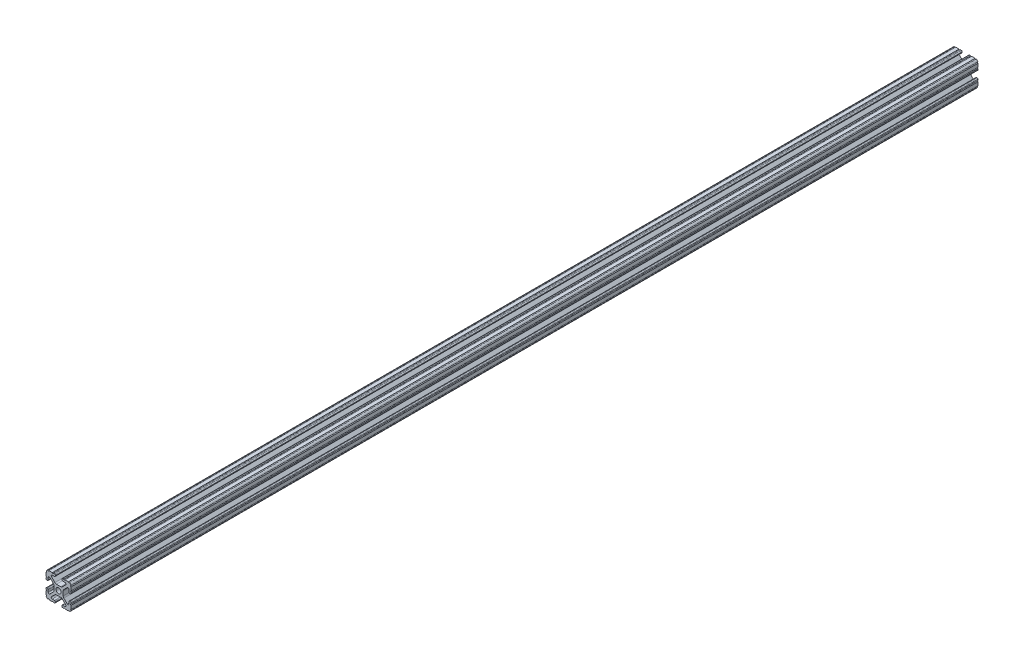
from build123d import *

# Parameters (mm, degrees)
BOSS_EXTRUDE1_DEPTH     = 457.2
SKETCH5_R               = 0.55245
CUT_EXTRUDE1_DEPTH      = 458.2
CUT_EXTRUDE1_DEPTH_BACK = 458.2


with BuildPart() as part:
    # Sketch4 → Boss-Extrude1 (new body, symmetric)
    with BuildSketch(Plane.XY):
        with BuildLine():
            Line((4.190365, -12.7), (10.11729625, -12.7))
            ThreePointArc((10.11729625, -12.7), (11.943543585, -11.943543585), (12.7, -10.11729625))
            Line((12.7, -10.11729625), (12.7, -4.190365))
            ThreePointArc((12.7, -4.190365), (12.42492494, -3.52627506), (11.760835, -3.2512))
            Line((11.760835, -3.2512), (11.429365, -3.2512))
            ThreePointArc((11.429365, -3.2512), (10.76527506, -3.52627506), (10.4902, -4.190365))
            Line((10.4902, -4.190365), (10.4902, -6.348478019))
            ThreePointArc((10.4902, -6.348478019), (9.830707141, -7.335478831), (8.666460301, -7.103895736))
            Line((8.666460301, -7.103895736), (5.299899128, -3.737334563))
            ThreePointArc((5.299899128, -3.737334563), (4.817571085, -3.015479634), (4.6482, -2.16399369))
            Line((4.6482, -2.16399369), (4.6482, 0))
            Line((4.6482, 0), (2.6035, 0))
            ThreePointArc((2.6035, 0), (1.840952505, -1.840952505), (0, -2.6035))
            Line((0, -2.6035), (0, -4.6482))
            Line((0, -4.6482), (2.16399369, -4.6482))
            ThreePointArc((2.16399369, -4.6482), (3.015479634, -4.817571085), (3.737334563, -5.299899128))
            Line((3.737334563, -5.299899128), (7.103895736, -8.666460301))
            ThreePointArc((7.103895736, -8.666460301), (7.335478831, -9.830707141), (6.348478019, -10.4902))
            Line((6.348478019, -10.4902), (4.190365, -10.4902))
            ThreePointArc((4.190365, -10.4902), (3.52627506, -10.76527506), (3.2512, -11.429365))
            Line((3.2512, -11.429365), (3.2512, -11.760835))
            ThreePointArc((3.2512, -11.760835), (3.52627506, -12.42492494), (4.190365, -12.7))
        make_face()
    extrude(amount=BOSS_EXTRUDE1_DEPTH, both=True)

    # Sketch5 → Cut-Extrude1 (cut, two sides)
    with BuildSketch(Plane.XY) as cut_extrude1_sk:
        with Locations((10.356153152, -12.7)):
            Circle(SKETCH5_R)
        with Locations((5.796028019, -12.7)):
            Circle(SKETCH5_R)
        with Locations((12.7, -10.356153152)):
            Circle(SKETCH5_R)
        with Locations((12.7, -5.796028019)):
            Circle(SKETCH5_R)
    extrude(amount=CUT_EXTRUDE1_DEPTH, mode=Mode.SUBTRACT)
    extrude(cut_extrude1_sk.sketch, amount=-CUT_EXTRUDE1_DEPTH_BACK, mode=Mode.SUBTRACT)

    # Mirror1: part across plane


with BuildPart() as part_1:
    add(part.part)
    add(part.part.mirror(Plane(origin=(0, 0, 0), x_dir=(0, 0, 1), z_dir=(1, 0, 0))))

    # Mirror2: part across plane


with BuildPart() as part_2:
    add(part_1.part)
    add(part_1.part.mirror(Plane.ZX))


solid = part_2.part
